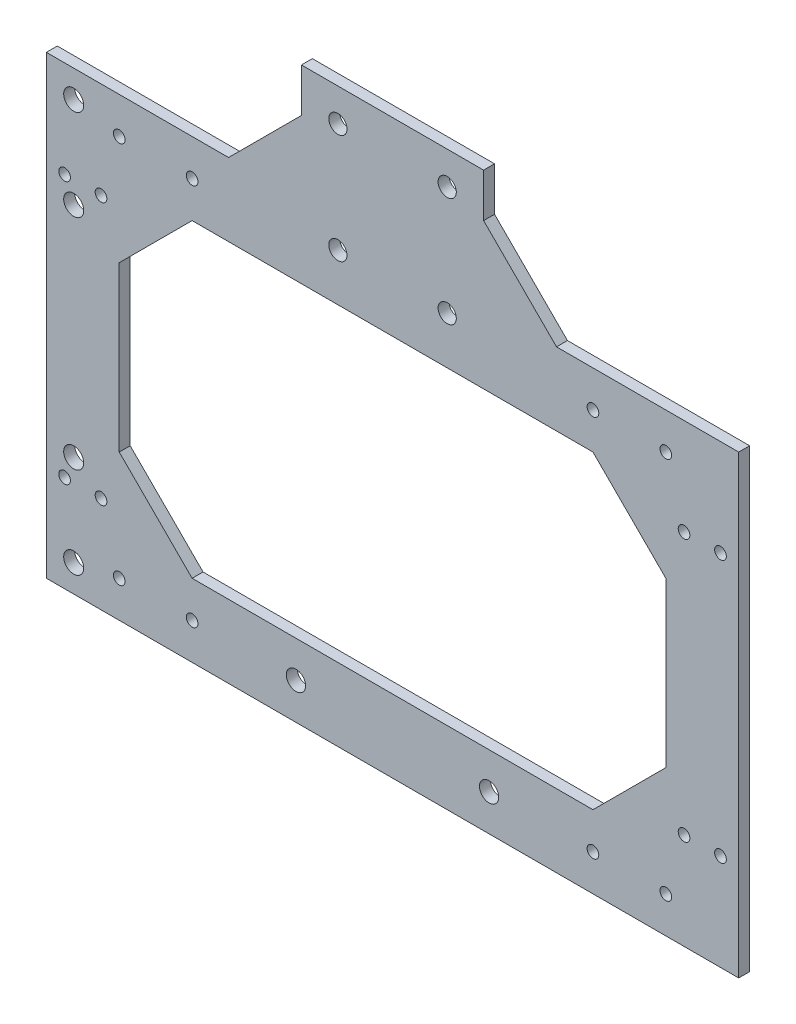
from build123d import *

# Parameters (mm, degrees)
SKETCH1_R          = 2.5
SKETCH1_R_2        = 1.6
SKETCH1_R_3        = 2.65
EXTRUDE1_DEPTH     = 3
CUT_EXTRUDE1_DEPTH = 3
SKETCH4_R          = 1.6
CUT_EXTRUDE2_DEPTH = 26
SKETCH5_R          = 2.75
CUT_EXTRUDE3_DEPTH = 10


with BuildPart() as part:
    # Sketch1 → Extrude1 (new body)
    with BuildSketch(Plane.XY):
        Polygon((95, -62.5), (95, 62.5), (45, 62.5), (25, 82.5), (25, 94.5), (-25, 94.5), (-25, 82.5), (-45, 62.5), (-95, 62.5), (-95, -62.5), align=None)
        with Locations((15, 85.5)):
            Circle(SKETCH1_R, mode=Mode.SUBTRACT)
        with Locations((-15, 85.5)):
            Circle(SKETCH1_R, mode=Mode.SUBTRACT)
        with Locations((-15, 55.5)):
            Circle(SKETCH1_R, mode=Mode.SUBTRACT)
        with Locations((15, 55.5)):
            Circle(SKETCH1_R, mode=Mode.SUBTRACT)
        with Locations((-75, 52.5)):
            Circle(SKETCH1_R_2, mode=Mode.SUBTRACT)
        with Locations((-55, 52.5)):
            Circle(SKETCH1_R_2, mode=Mode.SUBTRACT)
        with Locations((75, 52.5)):
            Circle(SKETCH1_R_2, mode=Mode.SUBTRACT)
        with Locations((55, 52.5)):
            Circle(SKETCH1_R_2, mode=Mode.SUBTRACT)
        with Locations((75, -52.5)):
            Circle(SKETCH1_R_2, mode=Mode.SUBTRACT)
        with Locations((55, -52.5)):
            Circle(SKETCH1_R_2, mode=Mode.SUBTRACT)
        with Locations((-55, -52.5)):
            Circle(SKETCH1_R_2, mode=Mode.SUBTRACT)
        with Locations((-75, -52.5)):
            Circle(SKETCH1_R_2, mode=Mode.SUBTRACT)
        with Locations((-26.5, -52.5)):
            Circle(SKETCH1_R_3, mode=Mode.SUBTRACT)
        with Locations((26.5, -52.5)):
            Circle(SKETCH1_R_3, mode=Mode.SUBTRACT)
        Polygon((75, -22.5), (75, 22.5), (55, 42.5), (-55, 42.5), (-75, 22.5), (-75, -22.5), (-55, -42.5), (55, -42.5), align=None, mode=Mode.SUBTRACT)
    extrude(amount=EXTRUDE1_DEPTH)

    # Sketch2 → Cut-Extrude1 (cut)
    with BuildSketch(Plane.XY.offset(3)):
        with BuildLine():
            ThreePointArc((90, -37.6), (91.6, -36), (90, -34.4))
            ThreePointArc((90, -34.4), (88.4, -36), (90, -37.6))
        make_face()
        with BuildLine():
            ThreePointArc((80, -37.6), (81.6, -36), (80, -34.4))
            ThreePointArc((80, -34.4), (78.4, -36), (80, -37.6))
        make_face()
        with BuildLine():
            ThreePointArc((90, 34.4), (91.6, 36), (90, 37.6))
            ThreePointArc((90, 37.6), (88.4, 36), (90, 34.4))
        make_face()
        with BuildLine():
            ThreePointArc((80, 34.4), (81.6, 36), (80, 37.6))
            ThreePointArc((80, 37.6), (78.4, 36), (80, 34.4))
        make_face()
    extrude(amount=-CUT_EXTRUDE1_DEPTH, mode=Mode.SUBTRACT)

    # Sketch4 → Cut-Extrude2 (cut)
    with BuildSketch(Plane.XY.offset(3)):
        with Locations((-80, -36)):
            Circle(SKETCH4_R)
        with Locations((-90, -36)):
            Circle(SKETCH4_R)
        with Locations((-80, 36)):
            Circle(SKETCH4_R)
        with Locations((-90, 36)):
            Circle(SKETCH4_R)
    extrude(amount=-CUT_EXTRUDE2_DEPTH, mode=Mode.SUBTRACT)

    # Sketch5 → Cut-Extrude3 (cut)
    with BuildSketch(Plane.XY.offset(3)):
        with Locations((-87.5, -55)):
            Circle(SKETCH5_R)
        with Locations((-87.5, -30)):
            Circle(SKETCH5_R)
        with Locations((-87.5, 30)):
            Circle(SKETCH5_R)
        with Locations((-87.5, 55)):
            Circle(SKETCH5_R)
    extrude(amount=-CUT_EXTRUDE3_DEPTH, mode=Mode.SUBTRACT)


solid = part.part
